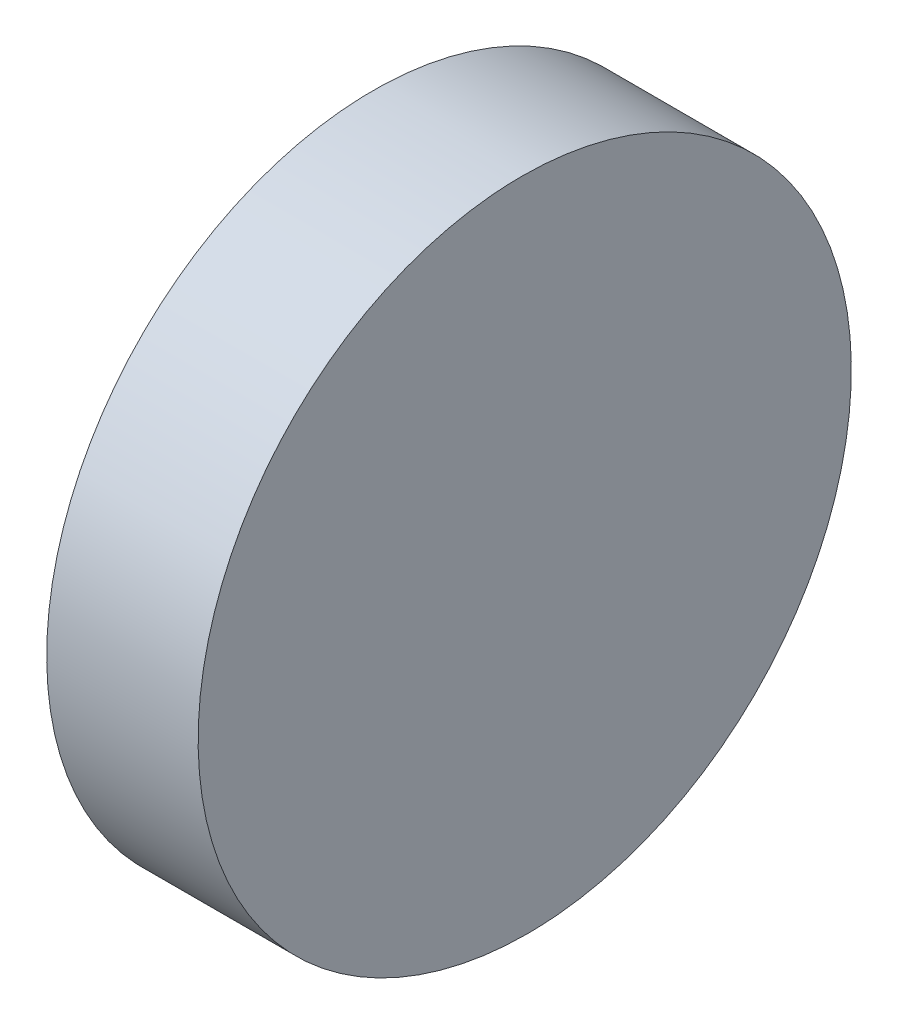
from build123d import *

# Parameters (mm, degrees)
EXTRUDE_1_DEPTH     = 25.4
CUT_EXTRUDE_1_DEPTH = 10


with BuildPart() as part:
    # 草图1 → 凸台-拉伸1 (new body)
    with BuildSketch(Plane.XY):
        Polygon((0, 12.7), (0, -12.7), (6, -12.7), (5.778337558, 12.7), align=None)
    extrude(amount=EXTRUDE_1_DEPTH)

    # 草图2 → 切除-拉伸1 (cut)
    with BuildSketch(Plane.ZY):
        with BuildLine():
            ThreePointArc((12.7, -12.7), (3.719743879, -8.980256121), (0, 0))
            Line((0, 0), (0, -12.7))
            Line((0, -12.7), (12.7, -12.7))
        make_face()
        with BuildLine():
            ThreePointArc((25.4, 0), (21.680256121, -8.980256121), (12.7, -12.7))
            Line((12.7, -12.7), (25.4, -12.7))
            Line((25.4, -12.7), (25.4, 0))
        make_face()
        with BuildLine():
            Line((25.4, 12.7), (12.7, 12.7))
            ThreePointArc((12.7, 12.7), (21.680256121, 8.980256121), (25.4, 0))
            Line((25.4, 0), (25.4, 12.7))
        make_face()
        with BuildLine():
            Line((12.7, 12.7), (0, 12.7))
            Line((0, 12.7), (0, 0))
            ThreePointArc((0, 0), (3.719743879, 8.980256121), (12.7, 12.7))
        make_face()
    extrude(amount=-CUT_EXTRUDE_1_DEPTH, mode=Mode.SUBTRACT)


solid = part.part
